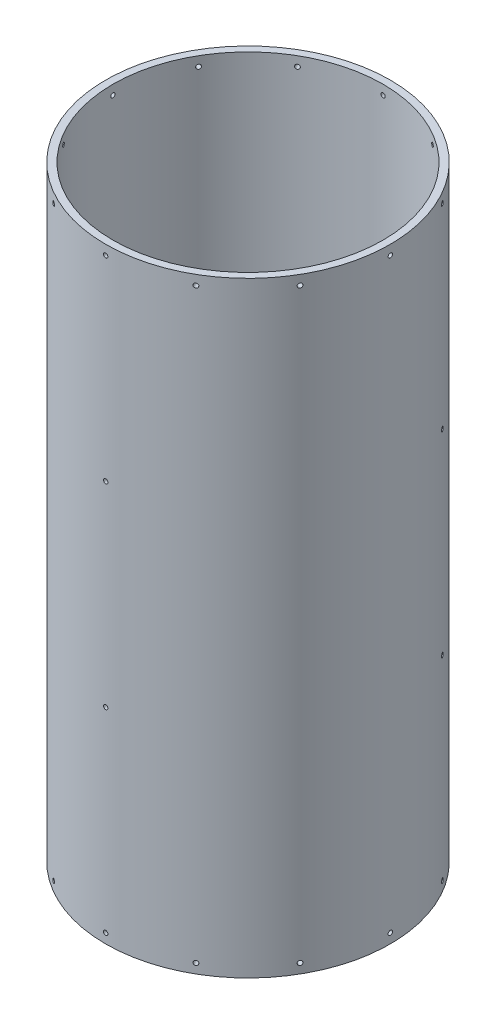
from build123d import *

# Parameters (mm, degrees)
SKETCH1_R                = 93.6625
SKETCH1_R_2              = 88.9
BOSS_EXTRUDE1_DEPTH      = 199.39
SKETCH3_R                = 1.4351
CUT_EXTRUDE1_DEPTH       = 19.304
CIRPATTERN1_COUNT        = 12
MIRROR1_COPY_1_SKETCH_R  = 1.4351
MIRROR1_COPY_1_DEPTH     = 19.304
MIRROR1_COPY_2_SKETCH_R  = 1.4351
MIRROR1_COPY_2_DEPTH     = 19.304
MIRROR1_COPY_3_SKETCH_R  = 1.4351
MIRROR1_COPY_3_DEPTH     = 19.304
MIRROR1_COPY_4_SKETCH_R  = 1.4351
MIRROR1_COPY_4_DEPTH     = 19.304
MIRROR1_COPY_5_SKETCH_R  = 1.4351
MIRROR1_COPY_5_DEPTH     = 19.304
MIRROR1_COPY_6_SKETCH_R  = 1.4351
MIRROR1_COPY_6_DEPTH     = 19.304
MIRROR1_COPY_7_SKETCH_R  = 1.4351
MIRROR1_COPY_7_DEPTH     = 19.304
MIRROR1_COPY_8_SKETCH_R  = 1.4351
MIRROR1_COPY_8_DEPTH     = 19.304
MIRROR1_COPY_9_SKETCH_R  = 1.4351
MIRROR1_COPY_9_DEPTH     = 19.304
MIRROR1_COPY_10_SKETCH_R = 1.4351
MIRROR1_COPY_10_DEPTH    = 19.304
MIRROR1_COPY_11_SKETCH_R = 1.4351
MIRROR1_COPY_11_DEPTH    = 19.304
SKETCH4_R                = 1.4351
CUT_EXTRUDE2_DEPTH       = 43.18
CIRPATTERN2_COUNT        = 3


with BuildPart() as part:
    # Sketch1 → Boss-Extrude1 (new body, symmetric)
    with BuildSketch(Plane(origin=(0, 0, 0), x_dir=(1, 0, 0), z_dir=(0, 1, 0))):
        Circle(SKETCH1_R)
        Circle(SKETCH1_R_2, mode=Mode.SUBTRACT)
    extrude(amount=BOSS_EXTRUDE1_DEPTH, both=True)

    # Sketch3 → Cut-Extrude1 (cut)
    with BuildSketch(Plane.XY.offset(93.6625)):
        with Locations((0, -193.04)):
            Circle(SKETCH3_R)
    cut_extrude1 = extrude(amount=-CUT_EXTRUDE1_DEPTH, mode=Mode.SUBTRACT)

    # CirPattern1: Cut-Extrude1 ×12 about axis
    cirpattern1_axis = Axis((0, 199.39, 0), (0, -1, 0))
    for i in range(1, CIRPATTERN1_COUNT):
        add(cut_extrude1.rotate(cirpattern1_axis, i * 360 / CIRPATTERN1_COUNT), mode=Mode.SUBTRACT)

    # Mirror1: Cut-Extrude1 across plane
    add(cut_extrude1.mirror(Plane.ZX), mode=Mode.SUBTRACT)

    # Mirror1 copy 1 sketch → Mirror1 copy 1 (cut)
    with BuildSketch(Plane(origin=(-46.83125, 0, 81.114104382), x_dir=(0.866025404, 0, 0.5), z_dir=(-0.5, 0, 0.866025404))):
        with Locations((0, 193.04)):
            Circle(MIRROR1_COPY_1_SKETCH_R)
    extrude(amount=-MIRROR1_COPY_1_DEPTH, mode=Mode.SUBTRACT)

    # Mirror1 copy 2 sketch → Mirror1 copy 2 (cut)
    with BuildSketch(Plane(origin=(-81.114104382, 0, 46.83125), x_dir=(0.5, 0, 0.866025404), z_dir=(-0.866025404, 0, 0.5))):
        with Locations((0, 193.04)):
            Circle(MIRROR1_COPY_2_SKETCH_R)
    extrude(amount=-MIRROR1_COPY_2_DEPTH, mode=Mode.SUBTRACT)

    # Mirror1 copy 3 sketch → Mirror1 copy 3 (cut)
    with BuildSketch(Plane.ZY.offset(93.6625)):
        with Locations((0, 193.04)):
            Circle(MIRROR1_COPY_3_SKETCH_R)
    extrude(amount=-MIRROR1_COPY_3_DEPTH, mode=Mode.SUBTRACT)

    # Mirror1 copy 4 sketch → Mirror1 copy 4 (cut)
    with BuildSketch(Plane(origin=(-81.114104382, 0, -46.83125), x_dir=(-0.5, 0, 0.866025404), z_dir=(-0.866025404, 0, -0.5))):
        with Locations((0, 193.04)):
            Circle(MIRROR1_COPY_4_SKETCH_R)
    extrude(amount=-MIRROR1_COPY_4_DEPTH, mode=Mode.SUBTRACT)

    # Mirror1 copy 5 sketch → Mirror1 copy 5 (cut)
    with BuildSketch(Plane(origin=(-46.83125, 0, -81.114104382), x_dir=(-0.866025404, 0, 0.5), z_dir=(-0.5, 0, -0.866025404))):
        with Locations((0, 193.04)):
            Circle(MIRROR1_COPY_5_SKETCH_R)
    extrude(amount=-MIRROR1_COPY_5_DEPTH, mode=Mode.SUBTRACT)

    # Mirror1 copy 6 sketch → Mirror1 copy 6 (cut)
    with BuildSketch(Plane(origin=(0, 0, -93.6625), x_dir=(-1, 0, 0), z_dir=(0, 0, -1))):
        with Locations((0, 193.04)):
            Circle(MIRROR1_COPY_6_SKETCH_R)
    extrude(amount=-MIRROR1_COPY_6_DEPTH, mode=Mode.SUBTRACT)

    # Mirror1 copy 7 sketch → Mirror1 copy 7 (cut)
    with BuildSketch(Plane(origin=(46.83125, 0, -81.114104382), x_dir=(-0.866025404, 0, -0.5), z_dir=(0.5, 0, -0.866025404))):
        with Locations((0, 193.04)):
            Circle(MIRROR1_COPY_7_SKETCH_R)
    extrude(amount=-MIRROR1_COPY_7_DEPTH, mode=Mode.SUBTRACT)

    # Mirror1 copy 8 sketch → Mirror1 copy 8 (cut)
    with BuildSketch(Plane(origin=(81.114104382, 0, -46.83125), x_dir=(-0.5, 0, -0.866025404), z_dir=(0.866025404, 0, -0.5))):
        with Locations((0, 193.04)):
            Circle(MIRROR1_COPY_8_SKETCH_R)
    extrude(amount=-MIRROR1_COPY_8_DEPTH, mode=Mode.SUBTRACT)

    # Mirror1 copy 9 sketch → Mirror1 copy 9 (cut)
    with BuildSketch(Plane(origin=(93.6625, 0, 0), x_dir=(0, 0, -1), z_dir=(1, 0, 0))):
        with Locations((0, 193.04)):
            Circle(MIRROR1_COPY_9_SKETCH_R)
    extrude(amount=-MIRROR1_COPY_9_DEPTH, mode=Mode.SUBTRACT)

    # Mirror1 copy 10 sketch → Mirror1 copy 10 (cut)
    with BuildSketch(Plane(origin=(81.114104382, 0, 46.83125), x_dir=(0.5, 0, -0.866025404), z_dir=(0.866025404, 0, 0.5))):
        with Locations((0, 193.04)):
            Circle(MIRROR1_COPY_10_SKETCH_R)
    extrude(amount=-MIRROR1_COPY_10_DEPTH, mode=Mode.SUBTRACT)

    # Mirror1 copy 11 sketch → Mirror1 copy 11 (cut)
    with BuildSketch(Plane(origin=(46.83125, 0, 81.114104382), x_dir=(0.866025404, 0, -0.5), z_dir=(0.5, 0, 0.866025404))):
        with Locations((0, 193.04)):
            Circle(MIRROR1_COPY_11_SKETCH_R)
    extrude(amount=-MIRROR1_COPY_11_DEPTH, mode=Mode.SUBTRACT)

    # Sketch4 → Cut-Extrude2 (cut)
    with BuildSketch(Plane.XY.offset(93.6625)):
        with Locations((0, 64.3636)):
            Circle(SKETCH4_R)
        with Locations((0, -64.3636)):
            Circle(SKETCH4_R)
    cut_extrude2 = extrude(amount=-CUT_EXTRUDE2_DEPTH, mode=Mode.SUBTRACT)

    # CirPattern2: Cut-Extrude2 ×3 about axis
    cirpattern2_axis = Axis((0, 199.39, 0), (0, -1, 0))
    for i in range(1, CIRPATTERN2_COUNT):
        add(cut_extrude2.rotate(cirpattern2_axis, i * 360 / CIRPATTERN2_COUNT), mode=Mode.SUBTRACT)


solid = part.part
